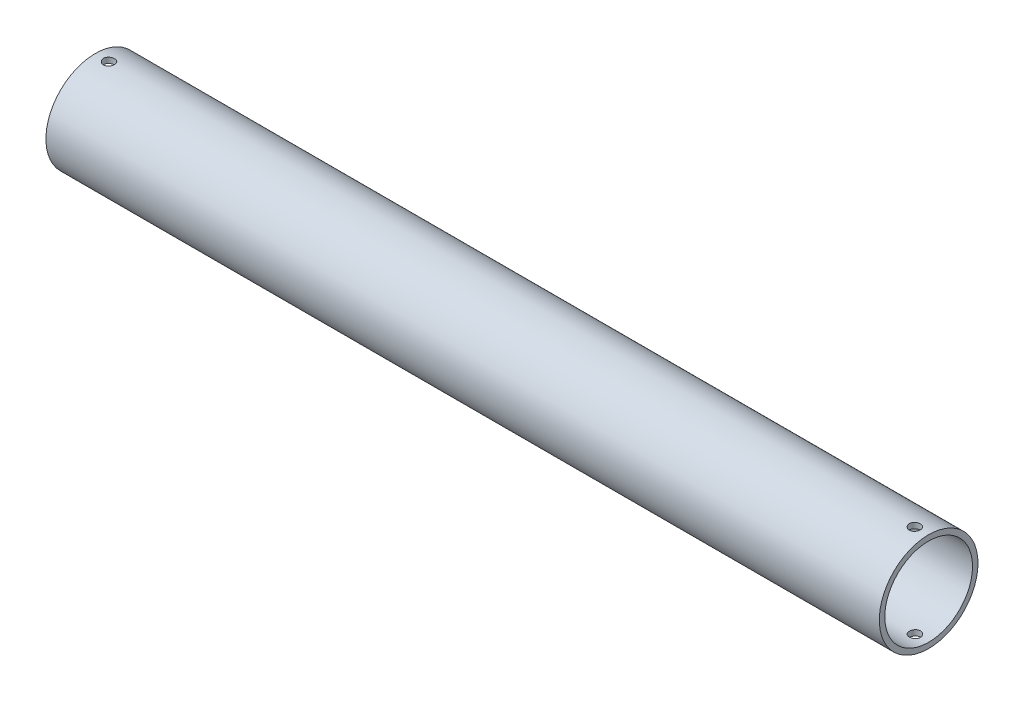
from build123d import *

# Parameters (mm, degrees)
SKETCH1_R               = 28.575
SKETCH1_R_2             = 25.4
BOSS_EXTRUDE1_DEPTH     = 482.6
SKETCH2_R               = 3.175
CUT_EXTRUDE1_DEPTH      = 29.575
CUT_EXTRUDE1_DEPTH_BACK = 29.575


with BuildPart() as part:
    # Sketch1 → Boss-Extrude1 (new body)
    with BuildSketch(Plane(origin=(0, 0, 0), x_dir=(0, 0, -1), z_dir=(1, 0, 0))):
        Circle(SKETCH1_R)
        Circle(SKETCH1_R_2, mode=Mode.SUBTRACT)
    extrude(amount=BOSS_EXTRUDE1_DEPTH)

    # Sketch2 → Cut-Extrude1 (cut, two sides)
    with BuildSketch(Plane(origin=(0, 0, 0), x_dir=(1, 0, 0), z_dir=(0, 1, 0))) as cut_extrude1_sk:
        with Locations((7.976402963, 0)):
            Circle(SKETCH2_R)
        with Locations((474.623597037, 0)):
            Circle(SKETCH2_R)
    extrude(amount=CUT_EXTRUDE1_DEPTH, mode=Mode.SUBTRACT)
    extrude(cut_extrude1_sk.sketch, amount=-CUT_EXTRUDE1_DEPTH_BACK, mode=Mode.SUBTRACT)


solid = part.part
